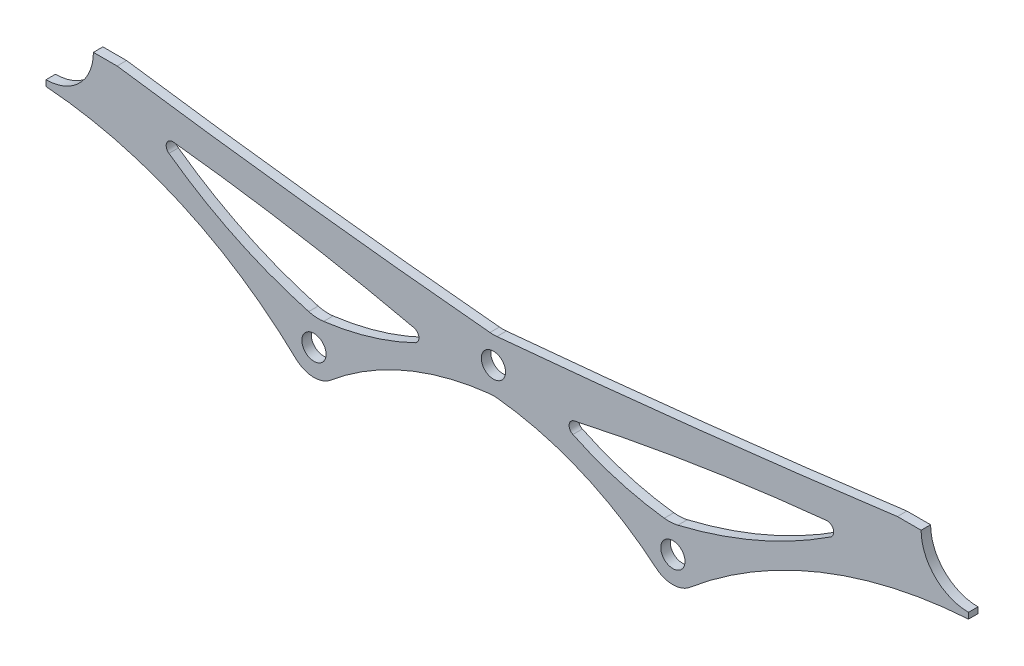
from build123d import *

# Parameters (mm, degrees)
PLANETARY_START           = -12.7
SKETCH1207_R              = 3.25
SKETCH1207_R_2            = 3.250000002
PLANETARY_INNER_TAB_DEPTH = 2.54
SMAL_ANGLE_FILLET_R       = 1.778
LARGE_ANGLE_FILLET_R      = 10.16


with BuildPart() as part:
    # Sketch1207 → Planetary Inner Tab (new body)
    with BuildSketch(Plane.XY.offset(PLANETARY_START)):
        with BuildLine():
            Line((-1653.472019465, 334.01), (-1653.472019465, 332.4225))
            ThreePointArc((-1653.472019465, 332.4225), (-1617.417278513, 323.366740441), (-1586.500499811, 302.724455656))
            ThreePointArc((-1586.500499811, 302.724455656), (-1581.895902138, 300.801653447), (-1577.180577212, 302.434197141))
            ThreePointArc((-1577.180577212, 302.434197141), (-1556.772529786, 314.866684199), (-1533.595059081, 320.685617601))
            ThreePointArc((-1533.595059081, 320.685617601), (-1510.41725967, 314.866679973), (-1490.008857704, 302.434160123))
            ThreePointArc((-1490.008857704, 302.434160123), (-1485.502791315, 300.798266511), (-1481.000799136, 302.445339259))
            ThreePointArc((-1481.000799136, 302.445339259), (-1446.058878011, 323.434373498), (-1406.300973236, 332.4225))
            Line((-1406.300973236, 332.4225), (-1406.300973236, 334.01))
            ThreePointArc((-1406.300973236, 334.01), (-1415.281229357, 337.729743879), (-1419.000973236, 346.71))
            Line((-1419.000973236, 346.71), (-1425.350973236, 346.71))
            ThreePointArc((-1425.350973236, 346.71), (-1479.405888247, 340.173785728), (-1533.583149601, 334.74421061))
            ThreePointArc((-1533.583149601, 334.744210609), (-1584.077440056, 340.096278026), (-1634.422019465, 346.71))
            Line((-1634.422019465, 346.71), (-1640.772019465, 346.71))
            ThreePointArc((-1640.772019465, 346.71), (-1644.491763344, 337.729743879), (-1653.472019465, 334.01))
        make_face()
        with Locations((-1581.678000655, 307.798261121)):
            Circle(SKETCH1207_R, mode=Mode.SUBTRACT)
        with Locations((-1485.511478414, 307.798261121)):
            Circle(SKETCH1207_R, mode=Mode.SUBTRACT)
        with BuildLine():
            ThreePointArc((-1581.138275137, 314.881124344), (-1604.565453937, 323.676576229), (-1625.585402649, 337.254294614))
            ThreePointArc((-1625.585402649, 337.254294614), (-1587.708607657, 332.221823862), (-1550.251821341, 324.674207047))
            ThreePointArc((-1550.251821341, 324.674207047), (-1565.191775687, 318.190391811), (-1581.138275137, 314.881124344))
        make_face(mode=Mode.SUBTRACT)
        with Locations((-1533.595063997, 327.714985503)):
            Circle(SKETCH1207_R_2, mode=Mode.SUBTRACT)
        with BuildLine():
            ThreePointArc((-1516.716796741, 324.550332905), (-1477.373328625, 332.055126671), (-1437.619544261, 336.940517311))
            ThreePointArc((-1437.619544261, 336.940517311), (-1460.647521819, 323.41294144), (-1485.95203842, 314.871015491))
            ThreePointArc((-1485.95203842, 314.871015491), (-1501.829474856, 318.137183344), (-1516.716796741, 324.550332905))
        make_face(mode=Mode.SUBTRACT)
    extrude(amount=-PLANETARY_INNER_TAB_DEPTH)

    # Smal Angle Fillet
    smal_angle_fillet_edges = [part.edges().sort_by_distance(p)[0] for p in [
        (-1550.251821341, 324.674207047, -13.97),
        (-1625.585402649, 337.254294614, -13.97),
        (-1437.619544261, 336.940517311, -13.97),
        (-1516.716796741, 324.550332905, -13.97),
    ]]
    fillet(smal_angle_fillet_edges, radius=SMAL_ANGLE_FILLET_R)

    # Large Angle Fillet
    large_angle_fillet_edges = [part.edges().sort_by_distance(p)[0] for p in [
        (-1581.138275137, 314.881124344, -13.97),
        (-1533.595059081, 320.685617601, -13.97),
        (-1533.583149601, 334.744210609, -13.97),
        (-1485.95203842, 314.871015491, -13.97),
    ]]
    fillet(large_angle_fillet_edges, radius=LARGE_ANGLE_FILLET_R)


solid = part.part
